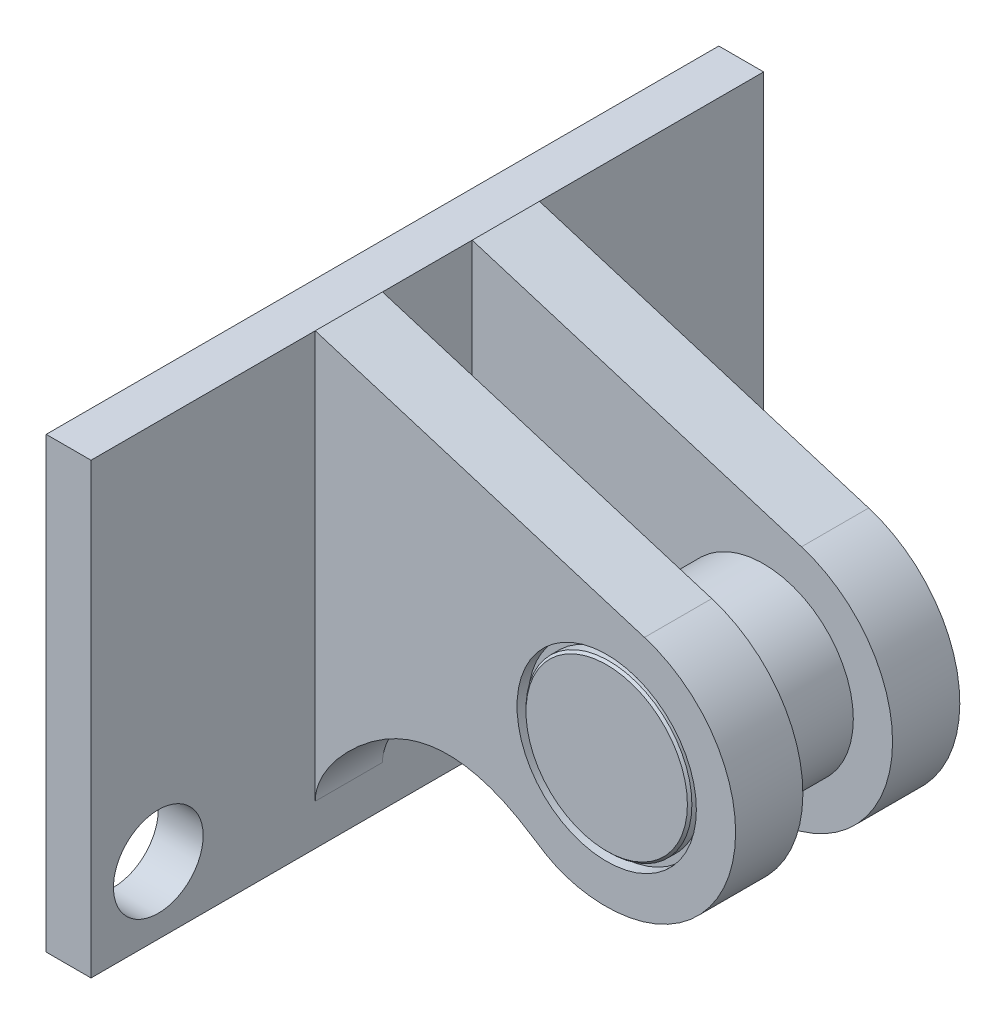
from build123d import *

# Parameters (mm, degrees)
CROQUIS2_W              = 30
CROQUIS2_H              = 20
SALIENTE_EXTRUIR1_DEPTH = 2
CROQUIS3_R              = 4
SALIENTE_EXTRUIR2_DEPTH = 3
CORTAR_EXTRUIR1_REACH   = 4
CROQUIS4_R              = 2
CROQUIS5_R              = 4
SALIENTE_EXTRUIR3_DEPTH = 10
CROQUIS6_R              = 4
CROQUIS6_R_2            = 3.7
CORTAR_EXTRUIR2_DEPTH   = 0.5
CHAFL_N1_SIZE           = 0.1
CHAFL_N2_SIZE           = 0.1


with BuildPart() as part:
    # Croquis2 → Saliente-Extruir1 (new body)
    with BuildSketch(Plane(origin=(4.659796597, 0, 0), x_dir=(0, 0, -1), z_dir=(1, 0, 0))):
        with Locations((0, -12.005778573)):
            Rectangle(CROQUIS2_W, CROQUIS2_H)
    extrude(amount=SALIENTE_EXTRUIR1_DEPTH)

    # Croquis3 → Saliente-Extruir2 (add)
    with BuildSketch(Plane.XY.offset(2)):
        with BuildLine():
            Line((6.659796597, -2.005778573), (6.659796597, -20.178909471))
            add(Edge.make_bspline(
                [(20.674797989, -17.665484588), (19.534879052, -17.869915578), (17.792697559, -17.715041339), (14.47778283, -15.367332549), (10.519354529, -14.525160484), (6.659796597, -19.008146523), (6.659796597, -20.178909471)],
                knots=[0, 0, 0, 0, 0.22934623, 0.306026125, 0.766798948, 1, 1, 1, 1], degree=3))
            ThreePointArc((20.674797989, -17.665484588), (25.39944116, -12.350713765), (21.345306956, -6.508365106))
            Line((21.345306956, -6.508365106), (6.659796597, -2.005778573))
        make_face()
        with Locations((19.659796597, -12.005778573)):
            Circle(CROQUIS3_R, mode=Mode.SUBTRACT)
    saliente_extruir2 = extrude(amount=SALIENTE_EXTRUIR2_DEPTH)

    # Simetría1: Saliente-Extruir2 across plane
    add(saliente_extruir2.mirror(Plane.XY))

    # Croquis4 → Cortar-Extruir1 (cut, up to next)
    with BuildSketch(Plane(origin=(6.659796597, 0, 0), x_dir=(0, 0, -1), z_dir=(1, 0, 0)), mode=Mode.PRIVATE) as cortar_extruir1_sk1:
        with Locations((-12, -19.005778573)):
            Circle(CROQUIS4_R)
    cortar_extruir1_tool1 = extrude(cortar_extruir1_sk1.sketch, amount=-CORTAR_EXTRUIR1_REACH, mode=Mode.PRIVATE) & part.part
    add(cortar_extruir1_tool1.solids().sort_by_distance((6.659797, -19.005779, 12))[0], mode=Mode.SUBTRACT)


with BuildPart() as body_2:
    # Croquis5 → Saliente-Extruir3 (new body)
    with BuildSketch(Plane.XY.offset(5)):
        with Locations((19.659796597, -12.005778573)):
            Circle(CROQUIS5_R)
    extrude(amount=-SALIENTE_EXTRUIR3_DEPTH)

    # Croquis6 → Cortar-Extruir2 (cut)
    with BuildSketch(Plane.XY.offset(5)):
        with Locations((19.659796597, -12.005778573)):
            Circle(CROQUIS6_R)
        with Locations((19.659796597, -12.005778573)):
            Circle(CROQUIS6_R_2, mode=Mode.SUBTRACT)
    cortar_extruir2 = extrude(amount=-CORTAR_EXTRUIR2_DEPTH, mode=Mode.SUBTRACT)

    # Chaflán1
    chafl_n1_edges = [body_2.edges().sort_by_distance(p)[0] for p in [
        (15.959796597, -12.005778573, 5),
    ]]
    chamfer(chafl_n1_edges, length=CHAFL_N1_SIZE)

    # Simetría3: Cortar-Extruir2 across plane
    add(cortar_extruir2.mirror(Plane.XY), mode=Mode.SUBTRACT)

    # Chaflán2
    chafl_n2_edges = [body_2.edges().sort_by_distance(p)[0] for p in [
        (15.959796597, -12.005778573, -5),
    ]]
    chamfer(chafl_n2_edges, length=CHAFL_N2_SIZE)


solid = Compound([part.part, body_2.part])
